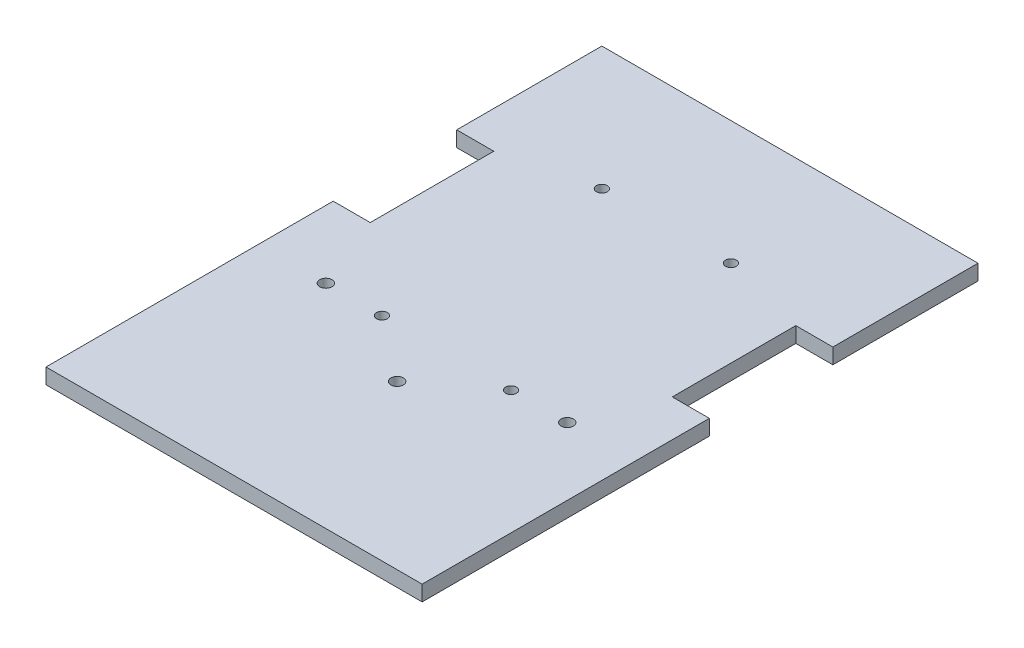
from build123d import *

# Parameters (mm, degrees)
SKETCH2_W           = 154.686
SKETCH2_H           = 228.6
BOSS_EXTRUDE1_DEPTH = 6.35
SKETCH1_R           = 2.2225
CUT_EXTRUDE1_DEPTH  = 6.35
SKETCH3_W           = 15.24
SKETCH3_H           = 50.8
CUT_EXTRUDE2_DEPTH  = 6.35
SKETCH8_R           = 2.54
CUT_EXTRUDE3_DEPTH  = 17.78


with BuildPart() as part:
    # Sketch2 → Boss-Extrude1 (new body)
    with BuildSketch(Plane(origin=(0, 0, 0), x_dir=(1, 0, 0), z_dir=(0, 1, 0))):
        with Locations((26.543, 26.944051327)):
            Rectangle(SKETCH2_W, SKETCH2_H)
    extrude(amount=BOSS_EXTRUDE1_DEPTH)

    # Sketch1 → Cut-Extrude1 (cut)
    with BuildSketch(Plane(origin=(0, 0, 0), x_dir=(1, 0, 0), z_dir=(0, 1, 0))):
        with Locations((0, 90.444051327)):
            Circle(SKETCH1_R)
        with Locations((53.086, 90.444051327)):
            Circle(SKETCH1_R)
        Circle(SKETCH1_R)
        with Locations((53.086, 0)):
            Circle(SKETCH1_R)
    extrude(amount=CUT_EXTRUDE1_DEPTH, mode=Mode.SUBTRACT)

    # Sketch3 → Cut-Extrude2 (cut)
    with BuildSketch(Plane(origin=(0, 6.35, 0), x_dir=(1, 0, 0), z_dir=(0, 1, 0))):
        with Locations((96.266, 56.154051327)):
            Rectangle(SKETCH3_W, SKETCH3_H)
        with Locations((-43.18, 56.154051327)):
            Rectangle(SKETCH3_W, SKETCH3_H)
    extrude(amount=-CUT_EXTRUDE2_DEPTH, mode=Mode.SUBTRACT)

    # Sketch8 → Cut-Extrude3 (cut)
    with BuildSketch(Plane(origin=(0, 6.35, 0), x_dir=(1, 0, 0), z_dir=(0, 1, 0))):
        with Locations((26.550112, -20.29968)):
            Circle(SKETCH8_R)
        with Locations((-23.077082804, 0.02032)):
            Circle(SKETCH8_R)
        with Locations((76.177306804, 0.02032)):
            Circle(SKETCH8_R)
    extrude(amount=-CUT_EXTRUDE3_DEPTH, mode=Mode.SUBTRACT)


solid = part.part
